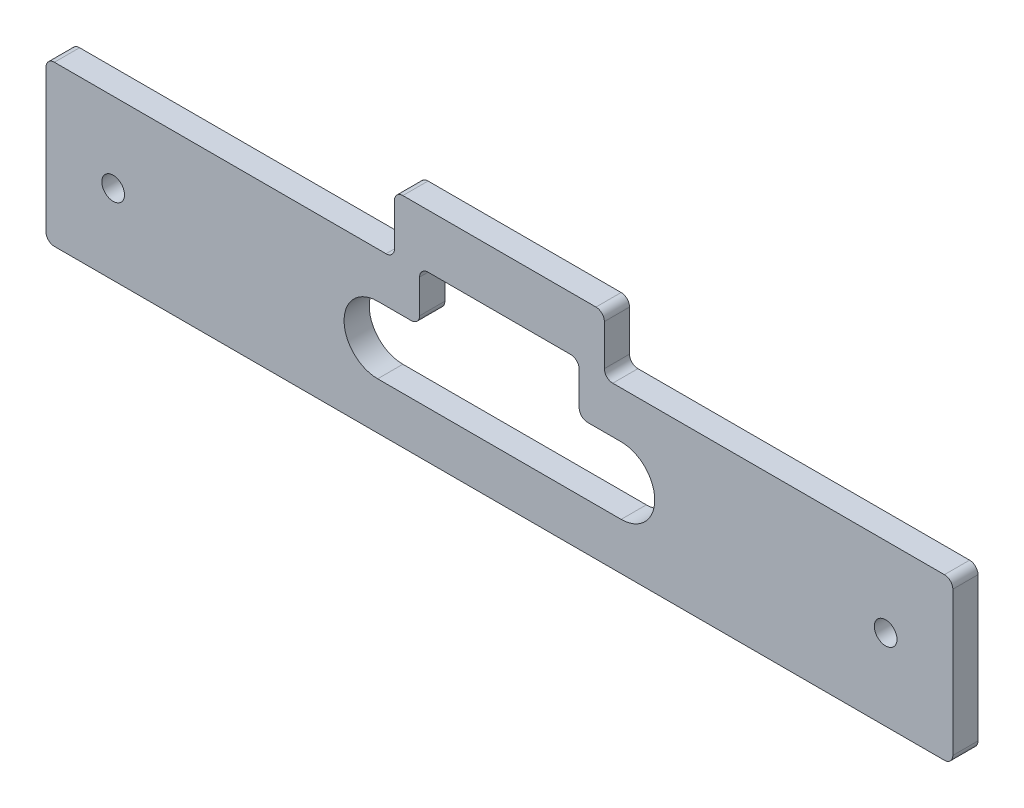
from build123d import *

# Parameters (mm, degrees)
BOSS_EXTRU_1_DEPTH      = 15
D_GAGEMENT_M121_D       = 13.5
ENL_V_MAT_EXTRU_8_DEPTH = 33
CONG_1_R                = 5
CONG_2_R                = 5
CONG_3_R                = 5


with BuildPart() as part:
    # Esquisse1 → Boss.-Extru.1 (new body)
    with BuildSketch(Plane.XY):
        Polygon((0, 95), (207.5, 95), (207.5, 130), (332.5, 130), (332.5, 95.731450782), (539.999504611, 95.731450782), (539.999504611, 0), (0, 0), align=None)
    extrude(amount=BOSS_EXTRU_1_DEPTH)

    # Dégagement M121 (through all)
    with Locations(Plane(origin=(0, 0, 0), x_dir=(-1, 0, 0), z_dir=(0, 0, -1))):
        with Locations((-40, 47.5), (-499.999504611, 48.231450782)):
            Hole(D_GAGEMENT_M121_D / 2)

    # Esquisse20 → Enlèv. mat.-Extru.8 (cut)
    with BuildSketch(Plane(origin=(0, 0, 0), x_dir=(-1, 0, 0), z_dir=(0, 0, -1))):
        with BuildLine():
            Line((-197.499504611, 28), (-342.499504611, 28))
            ThreePointArc((-342.499504611, 28), (-362.499504611, 48), (-342.499504611, 68))
            Line((-342.499504611, 68), (-317.499504611, 68))
            Line((-317.499504611, 68), (-317.499504611, 98))
            Line((-317.499504611, 98), (-222.499504611, 98))
            Line((-222.499504611, 98), (-222.499504611, 68))
            Line((-222.499504611, 68), (-197.499504611, 68))
            ThreePointArc((-197.499504611, 68), (-177.499504611, 48), (-197.499504611, 28))
        make_face()
    extrude(amount=-ENL_V_MAT_EXTRU_8_DEPTH, mode=Mode.SUBTRACT)

    # Congé1
    cong_1_edges = [part.edges().sort_by_distance(p)[0] for p in [
        (207.5, 95, 7.5),
        (207.5, 130, 7.5),
        (332.5, 130, 7.5),
        (332.5, 95.731450782, 7.5),
    ]]
    fillet(cong_1_edges, radius=CONG_1_R)

    # Congé2
    cong_2_edges = [part.edges().sort_by_distance(p)[0] for p in [
        (317.499504611, 68, 7.5),
        (317.499504611, 98, 7.5),
        (222.499504611, 98, 7.5),
        (222.499504611, 68, 7.5),
    ]]
    fillet(cong_2_edges, radius=CONG_2_R)

    # Congé3
    cong_3_edges = [part.edges().sort_by_distance(p)[0] for p in [
        (0, 95, 7.5),
        (539.999504611, 95.731450782, 7.5),
        (539.999504611, 0, 7.5),
        (0, 0, 7.5),
    ]]
    fillet(cong_3_edges, radius=CONG_3_R)


solid = part.part
